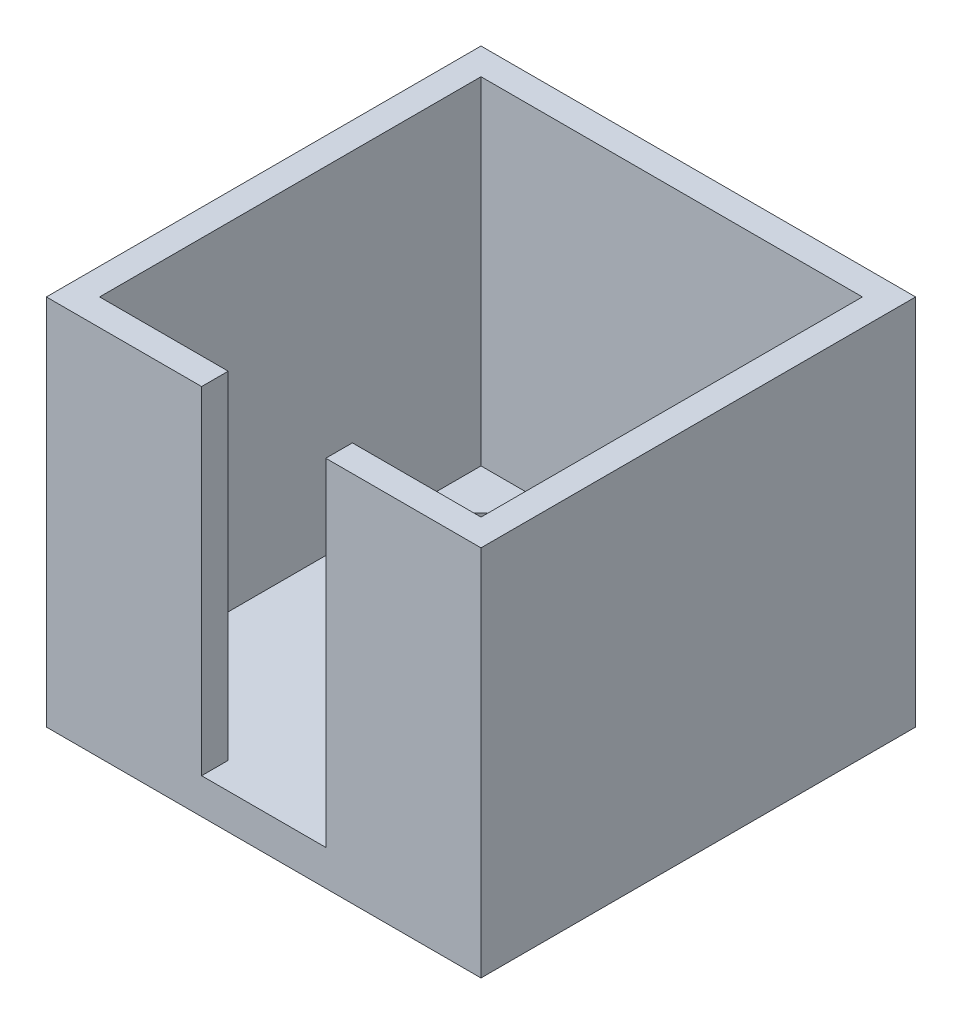
from build123d import *

# Parameters (mm, degrees)
ESQUISSE1_W             = 49
ESQUISSE1_H             = 49
ESQUISSE1_W_2           = 43
ESQUISSE1_H_2           = 43
ESQUISSE1_R             = 3.5
BOSS_EXTRU_1_DEPTH      = 4
ESQUISSE2_W             = 49
ESQUISSE2_H             = 49
ESQUISSE2_W_2           = 43
ESQUISSE2_H_2           = 43
BOSS_EXTRU_2_DEPTH      = 38
ESQUISSE3_W             = 14
ESQUISSE3_H             = 42
ENL_V_MAT_EXTRU_1_DEPTH = 3
ESQUISSE4_W             = 14
ESQUISSE4_H             = 4
BOSS_EXTRU_3_DEPTH      = 3


with BuildPart() as part:
    # Esquisse1 → Boss.-Extru.1 (new body)
    with BuildSketch(Plane(origin=(0, 0, 0), x_dir=(1, 0, 0), z_dir=(0, 1, 0))):
        with Locations((21.5, 21.5)):
            Rectangle(ESQUISSE1_W, ESQUISSE1_H)
        with Locations((21.5, 21.5)):
            Rectangle(ESQUISSE1_W_2, ESQUISSE1_H_2, mode=Mode.SUBTRACT)
        with Locations((21.5, 21.5)):
            Rectangle(ESQUISSE1_W_2, ESQUISSE1_H_2)
        with Locations(Location((35.928932188, 7.071067812, 0), (0, 0, 270))):
            Circle(ESQUISSE1_R, mode=Mode.SUBTRACT)
        with Locations(Location((7.071067812, 35.928932188, 0), (0, 0, 270))):
            Circle(ESQUISSE1_R, mode=Mode.SUBTRACT)
    extrude(amount=BOSS_EXTRU_1_DEPTH)

    # Esquisse2 → Boss.-Extru.2 (add)
    with BuildSketch(Plane(origin=(0, 4, 0), x_dir=(1, 0, 0), z_dir=(0, 1, 0))):
        with Locations((21.5, 21.5)):
            Rectangle(ESQUISSE2_W, ESQUISSE2_H)
        with Locations((21.5, 21.5)):
            Rectangle(ESQUISSE2_W_2, ESQUISSE2_H_2, mode=Mode.SUBTRACT)
    extrude(amount=BOSS_EXTRU_2_DEPTH)

    # Esquisse3 → Enlèv. mat.-Extru.1 (cut)
    with BuildSketch(Plane.XY.offset(3)):
        with Locations((21.5, 21)):
            Rectangle(ESQUISSE3_W, ESQUISSE3_H)
    extrude(amount=-ENL_V_MAT_EXTRU_1_DEPTH, mode=Mode.SUBTRACT)

    # Esquisse4 → Boss.-Extru.3 (add)
    with BuildSketch(Plane.XY):
        with Locations((21.5, 2)):
            Rectangle(ESQUISSE4_W, ESQUISSE4_H)
    extrude(amount=BOSS_EXTRU_3_DEPTH)


solid = part.part
